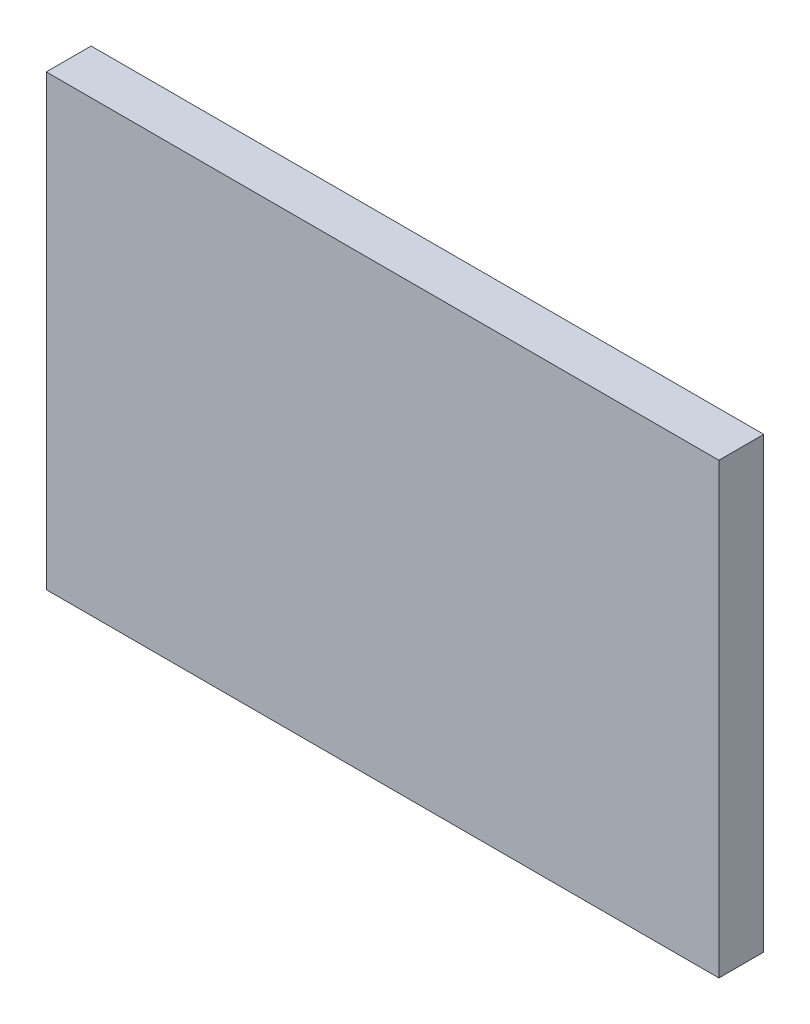
from build123d import *

# Parameters (mm, degrees)
SKETCH_1_W      = 150
SKETCH_1_H      = 100
EXTRUDE_1_DEPTH = 10


with BuildPart() as part:
    # Эскиз1 → Бобышка-Вытянуть1 (new body)
    with BuildSketch(Plane.XY):
        Rectangle(SKETCH_1_W, SKETCH_1_H)
    extrude(amount=EXTRUDE_1_DEPTH)


solid = part.part
